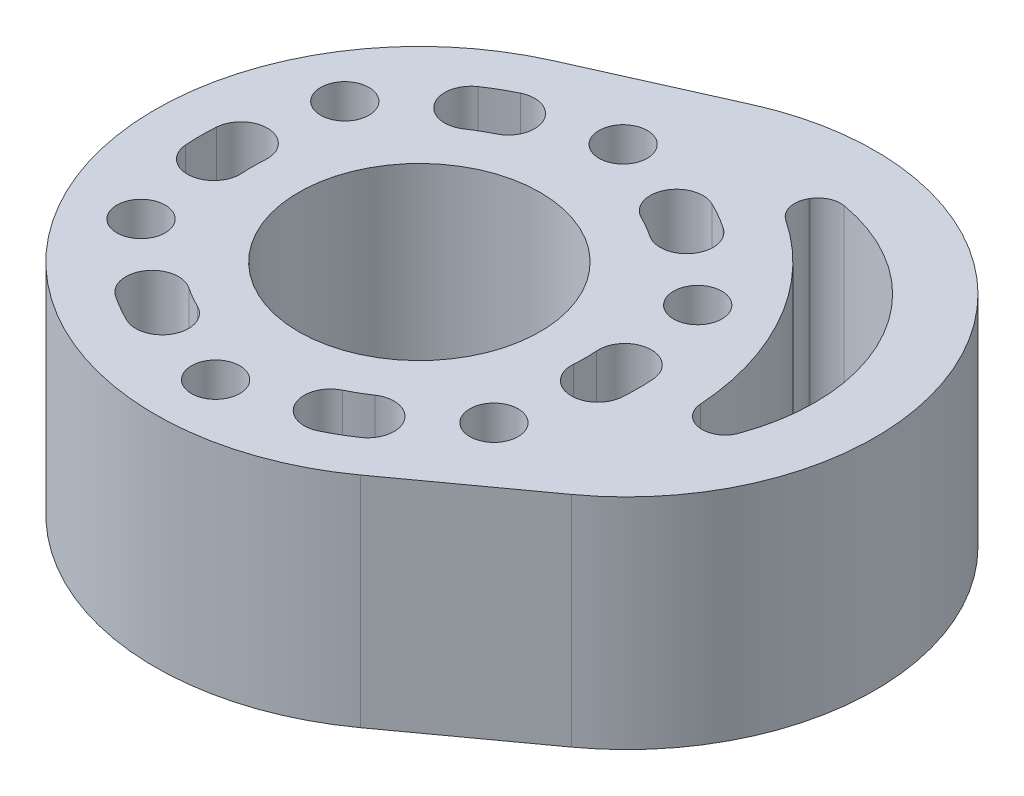
from build123d import *

# Parameters (mm, degrees)
SKETCH_1_R      = 1.6
SKETCH_1_R_2    = 8
EXTRUDE_1_DEPTH = 14.5


with BuildPart() as part:
    # 草图1 → 凸台-拉伸1 (new body)
    with BuildSketch(Plane(origin=(0, 7.25, 0), x_dir=(1, 0, 0), z_dir=(0, 1, 0))):
        with BuildLine():
            Line((10.270859413, -14.168960686), (18.367408376, -8.299898164))
            ThreePointArc((18.367408376, -8.299898164), (22.961692064, 13.256939094), (1.995781529, 20.056591338))
            Line((1.995781529, 20.056591338), (-7.135250193, 15.979305513))
            ThreePointArc((-7.135250193, 15.979305513), (-15.155444566, -8.75), (10.270859413, -14.168960686))
        make_face()
        with Locations((-11.691342951, -6.75)):
            Circle(SKETCH_1_R, mode=Mode.SUBTRACT)
        with Locations((-11.691342951, 6.75)):
            Circle(SKETCH_1_R, mode=Mode.SUBTRACT)
        with Locations((0, 13.5)):
            Circle(SKETCH_1_R, mode=Mode.SUBTRACT)
        with Locations((11.691342951, 6.75)):
            Circle(SKETCH_1_R, mode=Mode.SUBTRACT)
        with Locations((11.691342951, -6.75)):
            Circle(SKETCH_1_R, mode=Mode.SUBTRACT)
        with Locations((0, -13.5)):
            Circle(SKETCH_1_R, mode=Mode.SUBTRACT)
        Circle(SKETCH_1_R_2, mode=Mode.SUBTRACT)
        with BuildLine():
            Line((18.998716884, -0.241336031), (18.958263766, -0.241336031))
            ThreePointArc((18.958263766, -0.241336031), (17.933337503, 0.163435155), (17.461558732, 1.159295761))
            ThreePointArc((17.461558732, 1.159295761), (15.155444566, 8.75), (9.734758946, 14.542505571))
            ThreePointArc((9.734758946, 14.542505571), (9.108207748, 15.449008275), (9.27012875, 16.539006048))
            Line((9.27012875, 16.539006048), (9.290355309, 16.574039476))
            ThreePointArc((9.290355309, 16.574039476), (9.954159898, 17.182891337), (10.847026058, 17.301748995))
            ThreePointArc((10.847026058, 17.301748995), (19.497590449, 11.256939094), (20.407267188, 0.742925624))
            ThreePointArc((20.407267188, 0.742925624), (19.857900358, 0.029109677), (18.998716884, -0.241336031))
        make_face(mode=Mode.SUBTRACT)
        with BuildLine():
            ThreePointArc((4.813837212, -9.890751807), (5.5, -9.526279442), (6.158723721, -9.114281218))
            ThreePointArc((6.158723721, -9.114281218), (8.588519962, -9.584483547), (8.118317632, -12.014279788))
            ThreePointArc((8.118317632, -12.014279788), (7.25, -12.557368355), (6.345512688, -13.0378092))
            ThreePointArc((6.345512688, -13.0378092), (4.006146253, -12.230118241), (4.813837212, -9.890751807))
        make_face(mode=Mode.SUBTRACT)
        with BuildLine():
            ThreePointArc((-6.158723721, -9.114281218), (-5.5, -9.526279442), (-4.813837212, -9.890751807))
            ThreePointArc((-4.813837212, -9.890751807), (-4.006146253, -12.230118241), (-6.345512688, -13.0378092))
            ThreePointArc((-6.345512688, -13.0378092), (-7.25, -12.557368355), (-8.118317632, -12.014279788))
            ThreePointArc((-8.118317632, -12.014279788), (-8.588519962, -9.584483547), (-6.158723721, -9.114281218))
        make_face(mode=Mode.SUBTRACT)
        with BuildLine():
            ThreePointArc((-10.972560933, 0.776470588), (-11, 0), (-10.972560933, -0.776470588))
            ThreePointArc((-10.972560933, -0.776470588), (-12.594666215, -2.645634694), (-14.463830321, -1.023529412))
            ThreePointArc((-14.463830321, -1.023529412), (-14.5, 0), (-14.463830321, 1.023529412))
            ThreePointArc((-14.463830321, 1.023529412), (-12.594666215, 2.645634694), (-10.972560933, 0.776470588))
        make_face(mode=Mode.SUBTRACT)
        with BuildLine():
            ThreePointArc((-4.813837212, 9.890751807), (-5.5, 9.526279442), (-6.158723721, 9.114281218))
            ThreePointArc((-6.158723721, 9.114281218), (-8.588519962, 9.584483547), (-8.118317632, 12.014279788))
            ThreePointArc((-8.118317632, 12.014279788), (-7.25, 12.557368355), (-6.345512688, 13.0378092))
            ThreePointArc((-6.345512688, 13.0378092), (-4.006146253, 12.230118241), (-4.813837212, 9.890751807))
        make_face(mode=Mode.SUBTRACT)
        with BuildLine():
            ThreePointArc((6.158723721, 9.114281218), (5.5, 9.526279442), (4.813837212, 9.890751807))
            ThreePointArc((4.813837212, 9.890751807), (4.006146253, 12.230118241), (6.345512688, 13.0378092))
            ThreePointArc((6.345512688, 13.0378092), (7.25, 12.557368355), (8.118317632, 12.014279788))
            ThreePointArc((8.118317632, 12.014279788), (8.588519962, 9.584483547), (6.158723721, 9.114281218))
        make_face(mode=Mode.SUBTRACT)
        with BuildLine():
            ThreePointArc((10.972560933, -0.776470588), (11, 0), (10.972560933, 0.776470588))
            ThreePointArc((10.972560933, 0.776470588), (12.594666215, 2.645634694), (14.463830321, 1.023529412))
            ThreePointArc((14.463830321, 1.023529412), (14.5, 0), (14.463830321, -1.023529412))
            ThreePointArc((14.463830321, -1.023529412), (12.594666215, -2.645634694), (10.972560933, -0.776470588))
        make_face(mode=Mode.SUBTRACT)
    extrude(amount=-EXTRUDE_1_DEPTH)


solid = part.part
